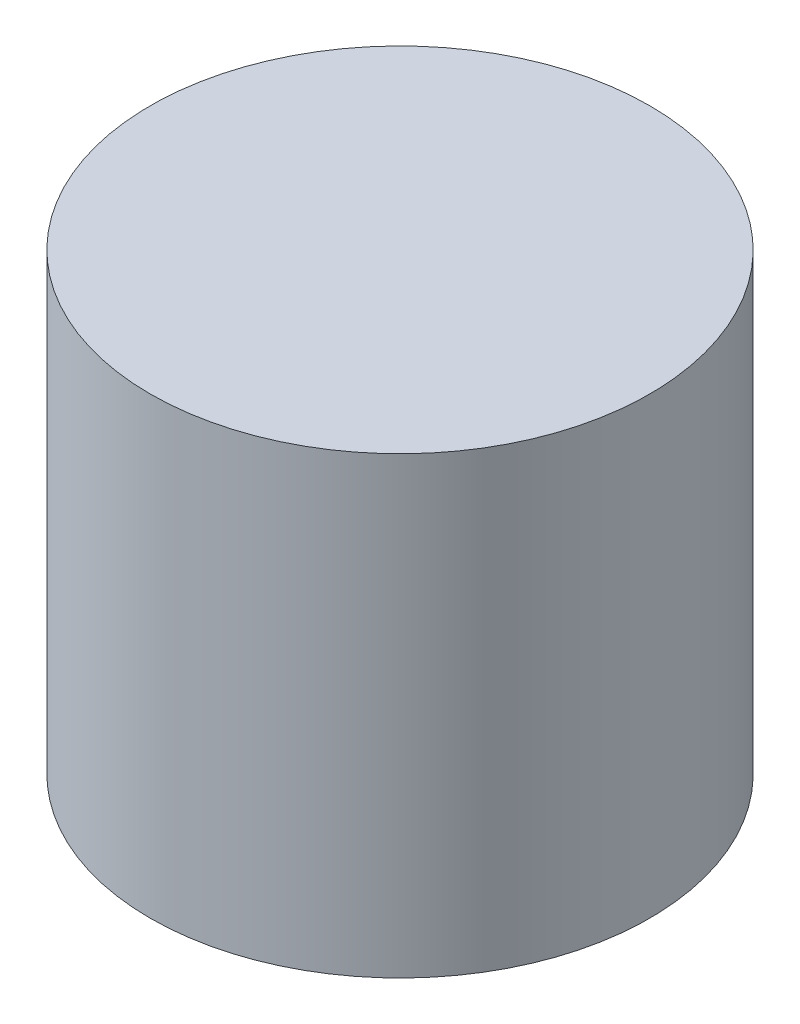
from build123d import *

# Parameters (mm, degrees)
SKETCH1_R           = 69.85
BOSS_EXTRUDE1_DEPTH = 127


with BuildPart() as part:
    # Sketch1 → Boss-Extrude1 (new body)
    with BuildSketch(Plane(origin=(0, 0, 0), x_dir=(1, 0, 0), z_dir=(0, 1, 0))):
        Circle(SKETCH1_R)
    extrude(amount=BOSS_EXTRUDE1_DEPTH)


solid = part.part
